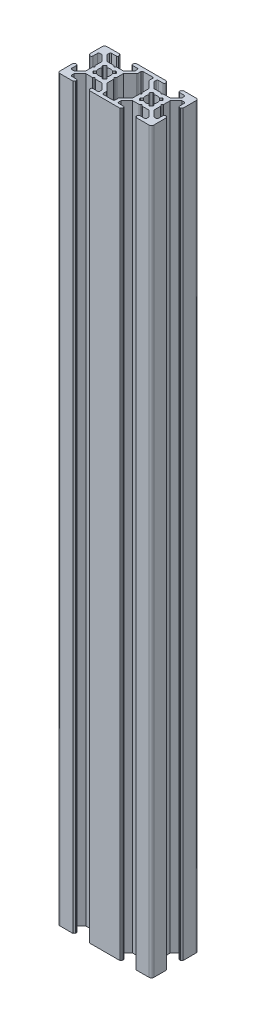
from build123d import *

# Parameters (mm, degrees)
BOSS_EXTRUDE1_DEPTH = 315
FILLET1_R           = 1
FILLET2_R           = 0.5
FILLET3_R           = 0.25
FILLET5_R           = 0.25
FILLET6_R           = 0.5
FILLET7_R           = 0.5
FILLET8_R           = 0.5


with BuildPart() as part:
    # Sketch2 → Boss-Extrude1 (new body)
    with BuildSketch(Plane(origin=(0, 0, 0), x_dir=(1, 0, 0), z_dir=(0, 1, 0))):
        with BuildLine():
            ThreePointArc((0, 13.5), (0.353553391, 13.353553391), (0.5, 13))
            Line((0.5, 13), (1.5, 13))
            Line((1.5, 13), (1.5, 16))
            Line((1.5, 16), (3, 16))
            Line((3, 16), (5.5, 13.5))
            Line((5.5, 13.5), (5.5, 10.5))
            Line((5.5, 10.5), (6, 10))
            Line((6, 10), (5.5, 9.5))
            Line((5.5, 9.5), (5.5, 6.5))
            Line((5.5, 6.5), (3, 4))
            Line((3, 4), (1.5, 4))
            Line((1.5, 4), (1.5, 7))
            Line((1.5, 7), (0.5, 7))
            ThreePointArc((0.5, 7), (0.353553391, 6.646446609), (0, 6.5))
            Line((0, 6.5), (0, 0))
            Line((0, 0), (6.5, 0))
            ThreePointArc((6.5, 0), (6.646446609, 0.353553391), (7, 0.5))
            Line((7, 0.5), (7, 1.5))
            Line((7, 1.5), (4, 1.5))
            Line((4, 1.5), (4, 3))
            Line((4, 3), (6.5, 5.5))
            Line((6.5, 5.5), (9.5, 5.5))
            Line((9.5, 5.5), (10, 6))
            Line((10, 6), (10.5, 5.5))
            Line((10.5, 5.5), (13.5, 5.5))
            Line((13.5, 5.5), (16, 3))
            Line((16, 3), (16, 1.5))
            Line((16, 1.5), (13, 1.5))
            Line((13, 1.5), (13, 0.5))
            ThreePointArc((13, 0.5), (13.353553391, 0.353553391), (13.5, 0))
            Line((13.5, 0), (26.5, 0))
            ThreePointArc((26.5, 0), (26.646446609, 0.353553391), (27, 0.5))
            Line((27, 0.5), (27, 1.5))
            Line((27, 1.5), (24, 1.5))
            Line((24, 1.5), (24, 3))
            Line((24, 3), (26.5, 5.5))
            Line((26.5, 5.5), (29.5, 5.5))
            Line((29.5, 5.5), (30, 6))
            Line((30, 6), (30.5, 5.5))
            Line((30.5, 5.5), (33.5, 5.5))
            Line((33.5, 5.5), (36, 3))
            Line((36, 3), (36, 1.5))
            Line((36, 1.5), (33, 1.5))
            Line((33, 1.5), (33, 0.5))
            ThreePointArc((33, 0.5), (33.353553391, 0.353553391), (33.5, 0))
            Line((33.5, 0), (40, 0))
            Line((40, 0), (40, 6.5))
            ThreePointArc((40, 6.5), (39.646446609, 6.646446609), (39.5, 7))
            Line((39.5, 7), (38.5, 7))
            Line((38.5, 7), (38.5, 4))
            Line((38.5, 4), (37, 4))
            Line((37, 4), (34.5, 6.5))
            Line((34.5, 6.5), (34.5, 9.5))
            Line((34.5, 9.5), (34, 10))
            Line((34, 10), (34.5, 10.5))
            Line((34.5, 10.5), (34.5, 13.5))
            Line((34.5, 13.5), (37, 16))
            Line((37, 16), (38.5, 16))
            Line((38.5, 16), (38.5, 13))
            Line((38.5, 13), (39.5, 13))
            ThreePointArc((39.5, 13), (39.646446609, 13.353553391), (40, 13.5))
            Line((40, 13.5), (40, 20))
            Line((40, 20), (33.5, 20))
            ThreePointArc((33.5, 20), (33.353553391, 19.646446609), (33, 19.5))
            Line((33, 19.5), (33, 18.5))
            Line((33, 18.5), (36, 18.5))
            Line((36, 18.5), (36, 17))
            Line((36, 17), (33.5, 14.5))
            Line((33.5, 14.5), (30.5, 14.5))
            Line((30.5, 14.5), (30, 14))
            Line((30, 14), (29.5, 14.5))
            Line((29.5, 14.5), (26.5, 14.5))
            Line((26.5, 14.5), (24, 17))
            Line((24, 17), (24, 18.5))
            Line((24, 18.5), (27, 18.5))
            Line((27, 18.5), (27, 19.5))
            ThreePointArc((27, 19.5), (26.646446609, 19.646446609), (26.5, 20))
            Line((26.5, 20), (13.5, 20))
            ThreePointArc((13.5, 20), (13.353553391, 19.646446609), (13, 19.5))
            Line((13, 19.5), (13, 18.5))
            Line((13, 18.5), (16, 18.5))
            Line((16, 18.5), (16, 17))
            Line((16, 17), (13.5, 14.5))
            Line((13.5, 14.5), (10.5, 14.5))
            Line((10.5, 14.5), (10, 14))
            Line((10, 14), (9.5, 14.5))
            Line((9.5, 14.5), (6.5, 14.5))
            Line((6.5, 14.5), (4, 17))
            Line((4, 17), (4, 18.5))
            Line((4, 18.5), (7, 18.5))
            Line((7, 18.5), (7, 19.5))
            ThreePointArc((7, 19.5), (6.646446609, 19.646446609), (6.5, 20))
            Line((6.5, 20), (0, 20))
            Line((0, 20), (0, 13.5))
        make_face()
        with BuildLine():
            Line((11.195582496, 12.195582496), (12, 13))
            Line((12, 13), (13, 12))
            Line((13, 12), (12.195582496, 11.195582496))
            ThreePointArc((12.195582496, 11.195582496), (12.422700584, 10.616864556), (12.5, 10))
            ThreePointArc((12.5, 10), (12.422700584, 9.383135444), (12.195582496, 8.804417504))
            Line((12.195582496, 8.804417504), (13, 8))
            Line((13, 8), (12, 7))
            Line((12, 7), (11.195582496, 7.804417504))
            ThreePointArc((11.195582496, 7.804417504), (10, 7.5), (8.804417504, 7.804417504))
            Line((8.804417504, 7.804417504), (8, 7))
            Line((8, 7), (7, 8))
            Line((7, 8), (7.804417504, 8.804417504))
            ThreePointArc((7.804417504, 8.804417504), (7.5, 10), (7.804417504, 11.195582496))
            Line((7.804417504, 11.195582496), (7, 12))
            Line((7, 12), (8, 13))
            Line((8, 13), (8.804417504, 12.195582496))
            ThreePointArc((8.804417504, 12.195582496), (10, 12.5), (11.195582496, 12.195582496))
        make_face(mode=Mode.SUBTRACT)
        Polygon((17.5, 16.5), (17.5, 18.5), (22.5, 18.5), (22.5, 16.5), (25.5, 13.5), (25.5, 10.5), (26, 10), (25.5, 9.5), (25.5, 6.5), (22.5, 3.5), (22.5, 1.5), (17.5, 1.5), (17.5, 3.5), (14.5, 6.5), (14.5, 9.5), (14, 10), (14.5, 10.5), (14.5, 13.5), align=None, mode=Mode.SUBTRACT)
        with BuildLine():
            Line((28.804417504, 7.804417504), (28, 7))
            Line((28, 7), (27, 8))
            Line((27, 8), (27.804417504, 8.804417504))
            ThreePointArc((27.804417504, 8.804417504), (27.5, 10), (27.804417504, 11.195582496))
            Line((27.804417504, 11.195582496), (27, 12))
            Line((27, 12), (28, 13))
            Line((28, 13), (28.804417504, 12.195582496))
            ThreePointArc((28.804417504, 12.195582496), (30, 12.5), (31.195582496, 12.195582496))
            Line((31.195582496, 12.195582496), (32, 13))
            Line((32, 13), (33, 12))
            Line((33, 12), (32.195582496, 11.195582496))
            ThreePointArc((32.195582496, 11.195582496), (32.422700584, 10.616864556), (32.5, 10))
            ThreePointArc((32.5, 10), (32.422700584, 9.383135444), (32.195582496, 8.804417504))
            Line((32.195582496, 8.804417504), (33, 8))
            Line((33, 8), (32, 7))
            Line((32, 7), (31.195582496, 7.804417504))
            ThreePointArc((31.195582496, 7.804417504), (30, 7.5), (28.804417504, 7.804417504))
        make_face(mode=Mode.SUBTRACT)
    extrude(amount=BOSS_EXTRUDE1_DEPTH)

    # Fillet1
    fillet1_edges = [part.edges().sort_by_distance(p)[0] for p in [
        (40, 157.5, 0),
        (0, 157.5, 0),
        (0, 157.5, -20),
        (40, 157.5, -20),
    ]]
    fillet(fillet1_edges, radius=FILLET1_R)

    # Fillet2
    fillet2_edges = [part.edges().sort_by_distance(p)[0] for p in [
        (7, 157.5, -18.5),
        (4, 157.5, -18.5),
        (9.5, 157.5, -14.5),
        (10.5, 157.5, -14.5),
        (16, 157.5, -18.5),
        (13, 157.5, -18.5),
    ]]
    fillet(fillet2_edges, radius=FILLET2_R)

    # Fillet3
    fillet3_edges = [part.edges().sort_by_distance(p)[0] for p in [
        (13, 157.5, -12),
        (12, 157.5, -13),
        (8, 157.5, -13),
        (7, 157.5, -12),
        (7, 157.5, -8),
        (8, 157.5, -7),
        (12, 157.5, -7),
        (13, 157.5, -8),
    ]]
    fillet(fillet3_edges, radius=FILLET3_R)

    # Fillet5
    fillet5_edges = [part.edges().sort_by_distance(p)[0] for p in [
        (27, 157.5, -8),
        (28, 157.5, -7),
        (32, 157.5, -7),
        (33, 157.5, -8),
        (33, 157.5, -12),
        (32, 157.5, -13),
        (28, 157.5, -13),
        (27, 157.5, -12),
    ]]
    fillet(fillet5_edges, radius=FILLET5_R)

    # Fillet6
    fillet6_edges = [part.edges().sort_by_distance(p)[0] for p in [
        (33, 157.5, -1.5),
        (36, 157.5, -1.5),
        (30.5, 157.5, -5.5),
        (29.5, 157.5, -5.5),
        (24, 157.5, -1.5),
        (27, 157.5, -1.5),
        (13, 157.5, -1.5),
        (16, 157.5, -1.5),
        (10.5, 157.5, -5.5),
        (9.5, 157.5, -5.5),
        (4, 157.5, -1.5),
        (7, 157.5, -1.5),
        (1.5, 157.5, -7),
        (1.5, 157.5, -4),
        (5.5, 157.5, -9.5),
        (5.5, 157.5, -10.5),
        (1.5, 157.5, -16),
        (1.5, 157.5, -13),
        (27, 157.5, -18.5),
        (24, 157.5, -18.5),
        (29.5, 157.5, -14.5),
        (30.5, 157.5, -14.5),
        (36, 157.5, -18.5),
        (33, 157.5, -18.5),
        (38.5, 157.5, -13),
        (38.5, 157.5, -16),
        (34.5, 157.5, -10.5),
        (34.5, 157.5, -9.5),
        (38.5, 157.5, -4),
        (38.5, 157.5, -7),
    ]]
    fillet(fillet6_edges, radius=FILLET6_R)

    # Fillet7
    fillet7_edges = [part.edges().sort_by_distance(p)[0] for p in [
        (22.5, 157.5, -16.5),
        (22.5, 157.5, -18.5),
        (17.5, 157.5, -18.5),
        (17.5, 157.5, -16.5),
        (17.5, 157.5, -3.5),
        (17.5, 157.5, -1.5),
        (22.5, 157.5, -1.5),
        (22.5, 157.5, -3.5),
    ]]
    fillet(fillet7_edges, radius=FILLET7_R)

    # Fillet8
    fillet8_edges = [part.edges().sort_by_distance(p)[0] for p in [
        (25.5, 157.5, -10.5),
        (14.5, 157.5, -10.5),
        (14.5, 157.5, -9.5),
        (25.5, 157.5, -9.5),
    ]]
    fillet(fillet8_edges, radius=FILLET8_R)


solid = part.part
